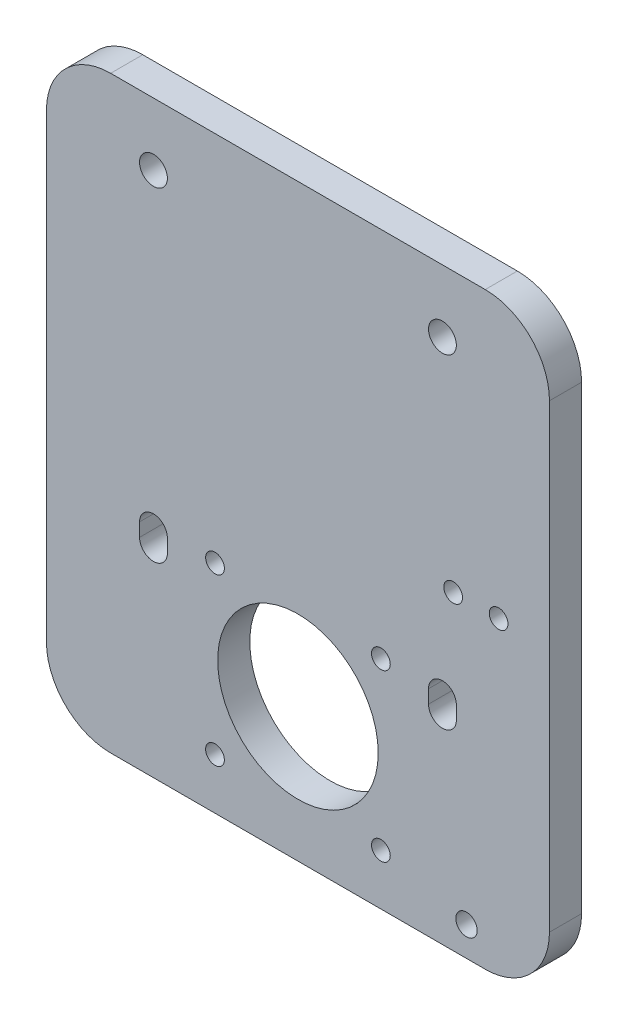
from build123d import *

# Parameters (mm, degrees)
MODEL_R                     = 15
MODEL_R_2                   = 2.6
BASE_DEPTH                  = 6
SKETCH2_R                   = 2
CABLETIEMOUNT_DEPTH         = 7
F_3_5_3_5_STEPPERMOUNT_D    = 3.5
F_3_5_3_5_CABLECHAINMOUNT_D = 3.5


with BuildPart() as part:
    # Model → Base (new body)
    with BuildSketch(Plane.XY):
        with BuildLine():
            Line((47, 98), (47, 12))
            ThreePointArc((47, 12), (43.485281374, 3.514718626), (35, 0))
            Line((35, 0), (-35, 0))
            ThreePointArc((-35, 0), (-43.485281374, 3.514718626), (-47, 12))
            Line((-47, 12), (-47, 98))
            ThreePointArc((-47, 98), (-43.485281374, 106.485281374), (-35, 110))
            Line((-35, 110), (35, 110))
            ThreePointArc((35, 110), (43.485281374, 106.485281374), (47, 98))
        make_face()
        with Locations((0, 25)):
            Circle(MODEL_R, mode=Mode.SUBTRACT)
        with Locations((27, 98.3)):
            Circle(MODEL_R_2, mode=Mode.SUBTRACT)
        with Locations((-27, 98.3)):
            Circle(MODEL_R_2, mode=Mode.SUBTRACT)
        with BuildLine():
            Line((-29.6, 40.1), (-29.6, 37.6))
            ThreePointArc((-29.6, 37.6), (-27, 35), (-24.4, 37.6))
            Line((-24.4, 37.6), (-24.4, 40.1))
            ThreePointArc((-24.4, 40.1), (-27, 42.7), (-29.6, 40.1))
        make_face(mode=Mode.SUBTRACT)
        with BuildLine():
            Line((29.6, 37.6), (29.6, 40.1))
            ThreePointArc((29.6, 40.1), (27, 42.7), (24.4, 40.1))
            Line((24.4, 40.1), (24.4, 37.6))
            ThreePointArc((24.4, 37.6), (27, 35), (29.6, 37.6))
        make_face(mode=Mode.SUBTRACT)
    extrude(amount=BASE_DEPTH)

    # Sketch2 → CableTieMount (cut, through all)
    with BuildSketch(Plane.XY.offset(6)):
        with Locations((31.5, 5.5)):
            Circle(SKETCH2_R)
    extrude(amount=-CABLETIEMOUNT_DEPTH, mode=Mode.SUBTRACT)

    # Ø3.5 (3.5) StepperMount (through all)
    with Locations(Plane.XY.offset(6)):
        with Locations((-15.5, 40.5), (-15.5, 9.5), (15.5, 9.5), (15.5, 40.5)):
            Hole(F_3_5_3_5_STEPPERMOUNT_D / 2)

    # Ø3.5 (3.5) CableChainMount (through all)
    with Locations(Plane(origin=(0, 0, 0), x_dir=(-1, 0, 0), z_dir=(0, 0, -1))):
        with Locations((-37.5, 58), (-29, 58)):
            Hole(F_3_5_3_5_CABLECHAINMOUNT_D / 2)


solid = part.part
